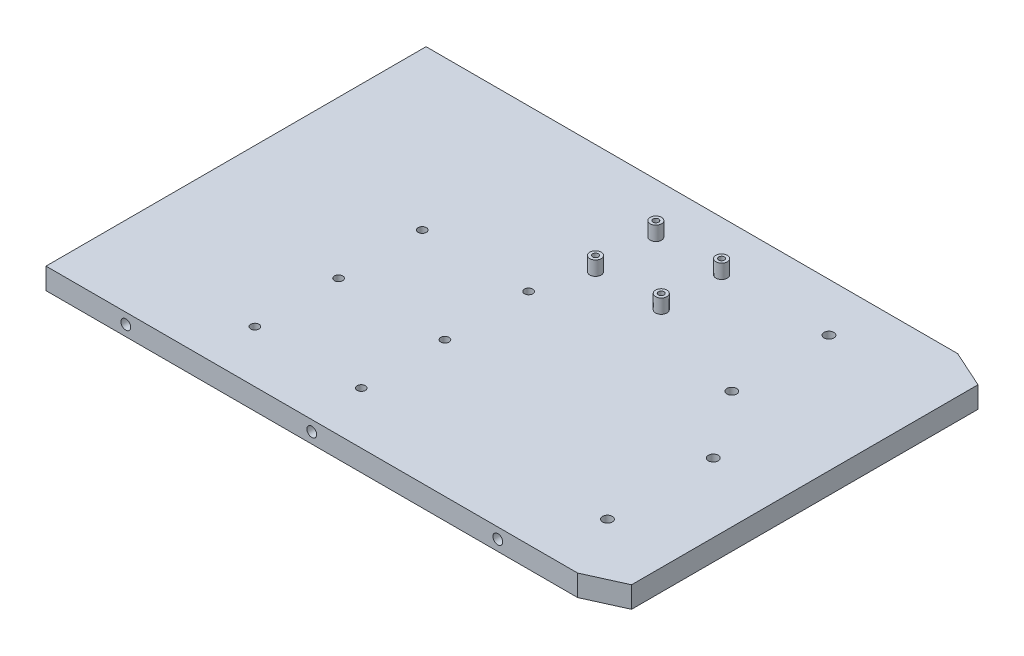
from build123d import *

# Parameters (mm, degrees)
BOSS_EXTRUDE1_DEPTH   = 10
SKETCH2_R             = 2.925
SKETCH2_R_2           = 3.455
SKETCH2_R_3           = 3.45
BOSS_EXTRUDE3_DEPTH   = 5
SKETCH3_R             = 4
SKETCH3_R_2           = 2
BOSS_EXTRUDE4_DEPTH   = 10
BOSS_EXTRUDE4_2_DEPTH = 10
BOSS_EXTRUDE4_3_DEPTH = 10
BOSS_EXTRUDE4_4_DEPTH = 10
SKETCH4_W             = 374.81
SKETCH4_H             = 15
SKETCH4_R             = 3.455
BOSS_EXTRUDE5_DEPTH   = 5.7
SKETCH5_W             = 374.81
SKETCH5_H             = 15
SKETCH5_R             = 3.455
BOSS_EXTRUDE6_DEPTH   = 5.7


with BuildPart() as part:
    # Sketch1 → Boss-Extrude1 (new body)
    with BuildSketch(Plane(origin=(0, 0, 0), x_dir=(1, 0, 0), z_dir=(0, 1, 0))):
        Polygon((0, 12.033084577), (0, 268.596915423), (374.81, 268.596915423), (374.81, 274.296915423), (401.01, 262.445), (401.01, 18.185), (374.81, 6.333084577), (374.81, 12.033084577), align=None)
    extrude(amount=BOSS_EXTRUDE1_DEPTH)



with BuildPart() as body_2:
    # Sketch2 → Boss-Extrude3 (new body)
    with BuildSketch(Plane(origin=(0, 10, 0), x_dir=(1, 0, 0), z_dir=(0, 1, 0))):
        Polygon((0, 268.596915423), (0, 12.033084577), (374.81, 12.033084577), (374.81, 6.333084577), (401.01, 18.185), (401.01, 262.445), (374.81, 274.296915423), (374.81, 268.596915423), align=None)
        with Locations((185.598476412, 102.016832694)):
            Circle(SKETCH2_R, mode=Mode.SUBTRACT)
        with Locations((185.598476412, 161.016832694)):
            Circle(SKETCH2_R, mode=Mode.SUBTRACT)
        with Locations((185.598476412, 43.016832694)):
            Circle(SKETCH2_R, mode=Mode.SUBTRACT)
        with Locations((110.598476412, 43.016832694)):
            Circle(SKETCH2_R, mode=Mode.SUBTRACT)
        with Locations((110.598476412, 102.016832694)):
            Circle(SKETCH2_R, mode=Mode.SUBTRACT)
        with Locations((110.598476412, 161.016832694)):
            Circle(SKETCH2_R, mode=Mode.SUBTRACT)
        with Locations((352.434052915, 124.380316665)):
            Circle(SKETCH2_R_2, mode=Mode.SUBTRACT)
        with Locations((352.434052915, 49.730316665)):
            Circle(SKETCH2_R_2, mode=Mode.SUBTRACT)
        with Locations((318.184052915, 240.18469423)):
            Circle(SKETCH2_R_3, mode=Mode.SUBTRACT)
        with Locations((318.184052915, 171.68469423)):
            Circle(SKETCH2_R_3, mode=Mode.SUBTRACT)
    extrude(amount=BOSS_EXTRUDE3_DEPTH)


with BuildPart() as body_3:
    # Sketch3 → Boss-Extrude4 (new body)
    with BuildSketch(Plane(origin=(0, 15, 0), x_dir=(1, 0, 0), z_dir=(0, 1, 0))):
        with Locations((197.186302821, 196.582002179)):
            Circle(SKETCH3_R)
        with Locations((197.186302821, 196.582002179)):
            Circle(SKETCH3_R_2, mode=Mode.SUBTRACT)
    extrude(amount=BOSS_EXTRUDE4_DEPTH)


with BuildPart() as body_4:
    # Sketch3 → Boss-Extrude4 2 (new body)
    with BuildSketch(Plane(origin=(0, 15, 0), x_dir=(1, 0, 0), z_dir=(0, 1, 0))):
        with Locations((197.186302821, 239.127002179)):
            Circle(SKETCH3_R)
        with Locations((197.186302821, 239.127002179)):
            Circle(SKETCH3_R_2, mode=Mode.SUBTRACT)
    extrude(amount=BOSS_EXTRUDE4_2_DEPTH)


with BuildPart() as body_5:
    # Sketch3 → Boss-Extrude4 3 (new body)
    with BuildSketch(Plane(origin=(0, 15, 0), x_dir=(1, 0, 0), z_dir=(0, 1, 0))):
        with Locations((243.541302821, 239.127002179)):
            Circle(SKETCH3_R)
        with Locations((243.541302821, 239.127002179)):
            Circle(SKETCH3_R_2, mode=Mode.SUBTRACT)
    extrude(amount=BOSS_EXTRUDE4_3_DEPTH)


with BuildPart() as body_6:
    # Sketch3 → Boss-Extrude4 4 (new body)
    with BuildSketch(Plane(origin=(0, 15, 0), x_dir=(1, 0, 0), z_dir=(0, 1, 0))):
        with Locations((243.541302821, 196.582002179)):
            Circle(SKETCH3_R)
        with Locations((243.541302821, 196.582002179)):
            Circle(SKETCH3_R_2, mode=Mode.SUBTRACT)
    extrude(amount=BOSS_EXTRUDE4_4_DEPTH)


with BuildPart() as part_1:
    add(part.part)

    add(body_2.part)  # Boss-Extrude5 merges body 2
    # Sketch4 → Boss-Extrude5 (add)
    with BuildSketch(Plane.XY.offset(-12.033084577)):
        with Locations((187.405, 7.5)):
            Rectangle(SKETCH4_W, SKETCH4_H)
        with Locations((187.405, 7.5)):
            Circle(SKETCH4_R, mode=Mode.SUBTRACT)
        with Locations((56.269425864, 7.5)):
            Circle(SKETCH4_R, mode=Mode.SUBTRACT)
        with Locations((318.540574136, 7.5)):
            Circle(SKETCH4_R, mode=Mode.SUBTRACT)
    extrude(amount=BOSS_EXTRUDE5_DEPTH)

    # Sketch5 → Boss-Extrude6 (add)
    with BuildSketch(Plane(origin=(0, 0, -268.596915423), x_dir=(-1, 0, 0), z_dir=(0, 0, -1))):
        with Locations((-187.405, 7.5)):
            Rectangle(SKETCH5_W, SKETCH5_H)
        with Locations((-187.405, 7.5)):
            Circle(SKETCH5_R, mode=Mode.SUBTRACT)
        with Locations((-318.540574136, 7.5)):
            Circle(SKETCH5_R, mode=Mode.SUBTRACT)
        with Locations((-56.269425864, 7.5)):
            Circle(SKETCH5_R, mode=Mode.SUBTRACT)
    extrude(amount=BOSS_EXTRUDE6_DEPTH)


solid = Compound([body_3.part, body_4.part, body_5.part, body_6.part, part_1.part])
